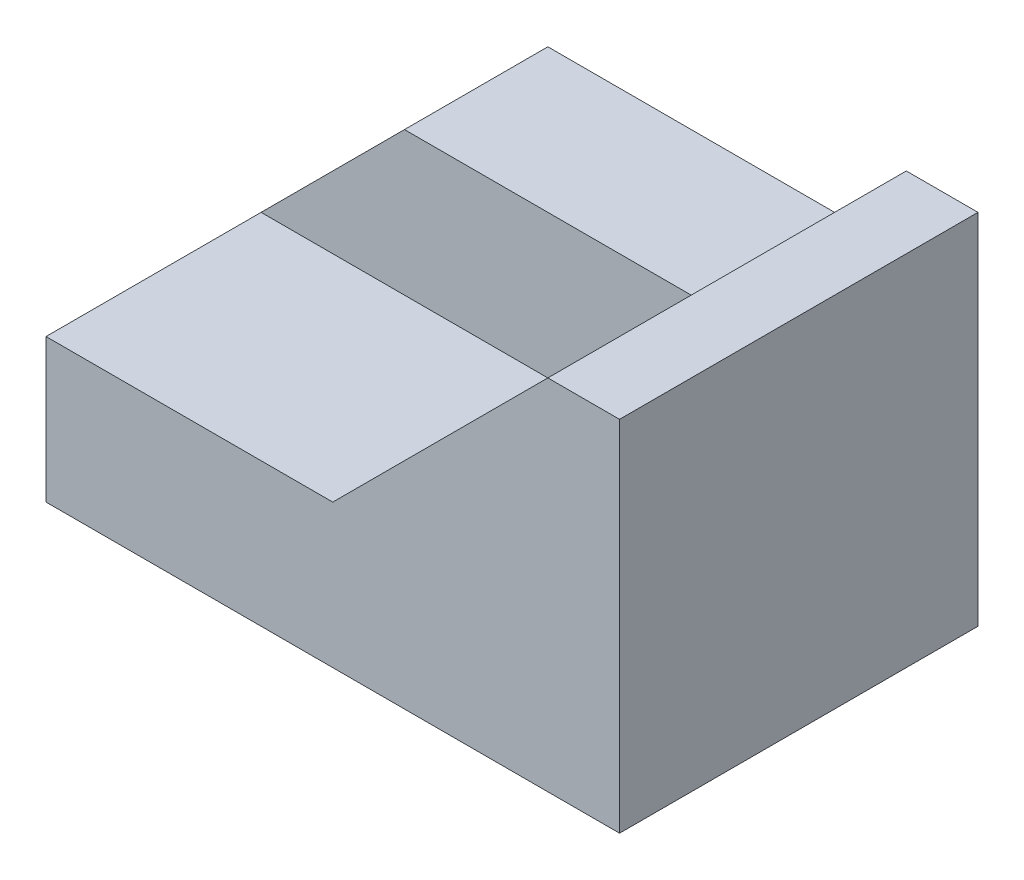
from build123d import *

# Parameters (mm, degrees)
SKETCH1_W           = 80
SKETCH1_H           = 50
BOSS_EXTRUDE1_DEPTH = 50
CUT_EXTRUDE1_DEPTH  = 50
CUT_EXTRUDE2_DEPTH  = 30


with BuildPart() as part:
    # Sketch1 → Boss-Extrude1 (new body)
    with BuildSketch(Plane.XY):
        with Locations((40, 25)):
            Rectangle(SKETCH1_W, SKETCH1_H)
    extrude(amount=BOSS_EXTRUDE1_DEPTH)

    # Sketch2 → Cut-Extrude1 (cut)
    with BuildSketch(Plane.XY.offset(50)):
        Polygon((70, 50), (60, 40), (20, 40), (0, 20), (0, 50), align=None)
    extrude(amount=-CUT_EXTRUDE1_DEPTH, mode=Mode.SUBTRACT)

    # Sketch3 → Cut-Extrude2 (cut)
    with BuildSketch(Plane.XY.offset(50)):
        Polygon((0, 20), (40, 20), (60, 40), (20, 40), align=None)
    extrude(amount=-CUT_EXTRUDE2_DEPTH, mode=Mode.SUBTRACT)


solid = part.part
